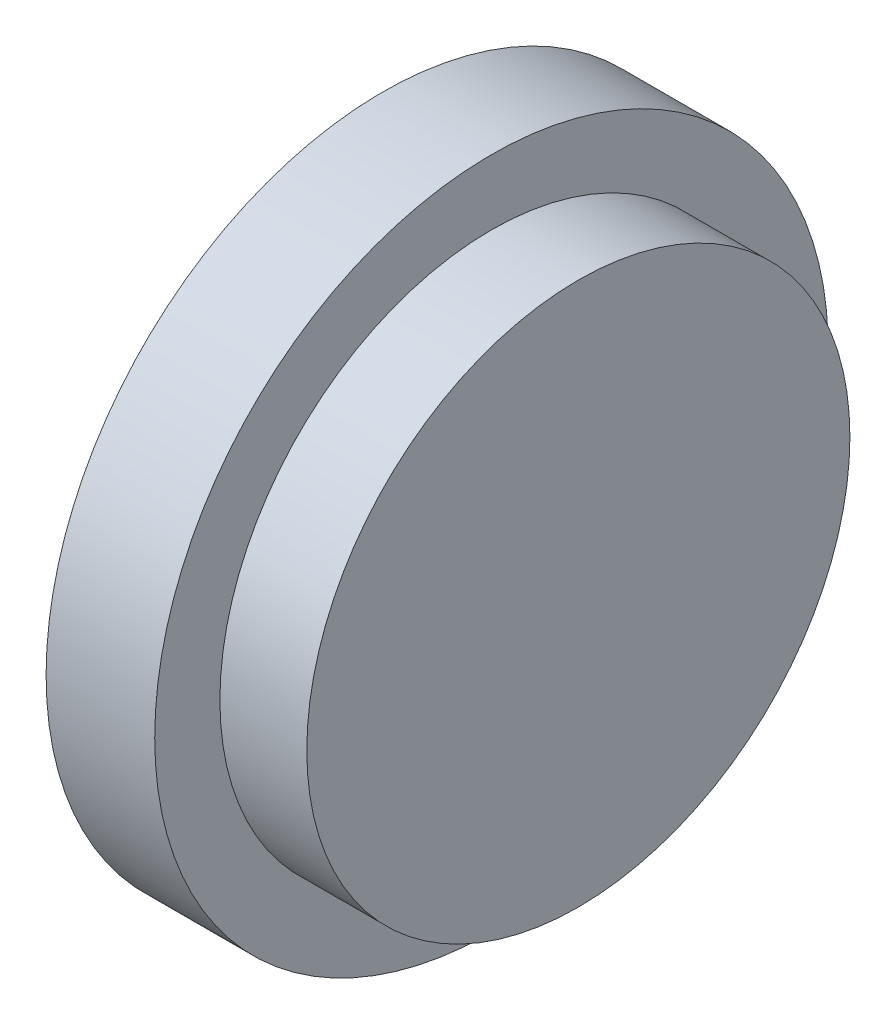
from build123d import *


with BuildPart() as part:
    # Sketch1 → Revolve1 (revolve)
    with BuildSketch(Plane.XY):
        Polygon((0, 0), (0, 15.5), (5, 15.5), (5, 12.5), (9, 12.5), (9, 0), align=None)
    revolve(axis=Axis((0, 0, 0), (1, 0, 0)))


solid = part.part
